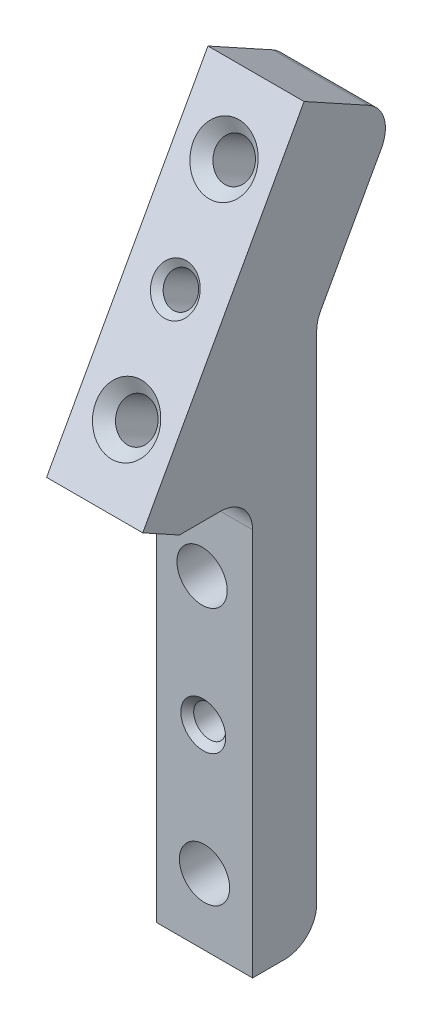
from build123d import *

# Parameters (mm, degrees)
BOSS_EXTRUDE1_DEPTH                    = 9.525
SKETCH2_W                              = 9.525
SKETCH2_H                              = 29.633356585
BOSS_EXTRUDE2_DEPTH                    = 10.5
BOSS_EXTRUDE3_DEPTH                    = 9.525
CUT_EXTRUDE1_DEPTH                     = 9.525
FILLET1_R                              = 3.175
F_10_24_TAPPED_HOLE1_D                 = 3.7973
F_10_24_TAPPED_HOLE1_DEPTH             = 12.83
F_10_24_TAPPED_HOLE1_CSINK_D           = 6.096
F_10_24_TAPPED_HOLE1_CSINK_ANGLE       = 90
F_10_24_TAPPED_HOLE1_TIP               = 1.140824014
F_1_8_0_125_DIAMETER_HOLE1_D           = 3.175
F_1_8_0_125_DIAMETER_HOLE1_DEPTH       = 8
F_1_8_0_125_DIAMETER_HOLE1_CSINK_D     = 4.445
F_1_8_0_125_DIAMETER_HOLE1_CSINK_ANGLE = 90
F_1_8_0_125_DIAMETER_HOLE1_TIP         = 0.953866233
F_10_CLEARANCE_HOLE1_D                 = 4.9784


with BuildPart() as part:
    # Sketch1 → Boss-Extrude1 (new body)
    with BuildSketch(Plane(origin=(0, 0, 0), x_dir=(0, 0, -1), z_dir=(1, 0, 0))):
        Polygon((0, 0), (13.510509947, 24.524806237), (7.948634247, 27.588796886), (-6.35, 1.633356585), (-6.35, -40), (0, -40), align=None)
    extrude(amount=BOSS_EXTRUDE1_DEPTH)

    # Sketch2 → Boss-Extrude2 (add)
    with BuildSketch(Plane(origin=(0, 3.063990649, 5.5618757), x_dir=(1, 0, 0), z_dir=(0, 0.482518212, 0.875885937))):
        with Locations((4.7625, 13.183321707)):
            Rectangle(SKETCH2_W, SKETCH2_H)
    extrude(amount=BOSS_EXTRUDE2_DEPTH)

    # Sketch3 → Boss-Extrude3 (add)
    with BuildSketch(Plane.ZY):
        Polygon((15.546802339, 6.699797816), (6.35, 1.633356585), (13.599802436, 1.633356585), (17.234729075, 3.635807167), align=None)
    extrude(amount=-BOSS_EXTRUDE3_DEPTH)

    # Sketch4 → Cut-Extrude1 (cut)
    with BuildSketch(Plane(origin=(9.525, 0, 0), x_dir=(0, 0, -1), z_dir=(1, 0, 0))):
        Polygon((13.510509947, 24.524806237), (7.948634247, 27.588796886), (0, 13.160125021), (0, 0), align=None)
    extrude(amount=-CUT_EXTRUDE1_DEPTH, mode=Mode.SUBTRACT)

    # Fillet1
    fillet1_edges = [part.edges().sort_by_distance(p)[0] for p in [
        (4.7625, -40, 0),
        (4.7625, 1.633356585, 6.35),
        (4.7625, 27.588796886, -7.948634247),
        (4.7625, 13.160125021, 0),
    ]]
    fillet(fillet1_edges, radius=FILLET1_R)

    # #10-24 Tapped Hole1
    with Locations(Plane(origin=(0, 8.130431879, 14.758678039), x_dir=(1, 0, 0), z_dir=(0, 0.482518212, 0.875885937))):
        with Locations((4.7625, 21.434240851), (4.7625, 1.434240851)):
            CounterSinkHole(F_10_24_TAPPED_HOLE1_D / 2, F_10_24_TAPPED_HOLE1_CSINK_D / 2, depth=F_10_24_TAPPED_HOLE1_DEPTH, counter_sink_angle=F_10_24_TAPPED_HOLE1_CSINK_ANGLE)
            with Locations((0, 0, -(F_10_24_TAPPED_HOLE1_DEPTH + F_10_24_TAPPED_HOLE1_TIP / 2))):  # 118° drill point
                Cone(0, F_10_24_TAPPED_HOLE1_D / 2, F_10_24_TAPPED_HOLE1_TIP, mode=Mode.SUBTRACT)

    # 1/8 (0.125) Diameter Hole1
    with Locations(Plane(origin=(0, 8.130431879, 14.758678039), x_dir=(1, 0, 0), z_dir=(0, 0.482518212, 0.875885937))):
        with Locations((4.7625, 11.434240851)):
            CounterSinkHole(F_1_8_0_125_DIAMETER_HOLE1_D / 2, F_1_8_0_125_DIAMETER_HOLE1_CSINK_D / 2, depth=F_1_8_0_125_DIAMETER_HOLE1_DEPTH, counter_sink_angle=F_1_8_0_125_DIAMETER_HOLE1_CSINK_ANGLE)
            with Locations((0, 0, -(F_1_8_0_125_DIAMETER_HOLE1_DEPTH + F_1_8_0_125_DIAMETER_HOLE1_TIP / 2))):  # 118° drill point
                Cone(0, F_1_8_0_125_DIAMETER_HOLE1_D / 2, F_1_8_0_125_DIAMETER_HOLE1_TIP, mode=Mode.SUBTRACT)

    # #10 Clearance Hole1 (through all)
    with Locations(Plane.XY.offset(6.35)):
        with Locations((4.7625, -33.418643415), (4.519767079, -8.018643415)):
            Hole(F_10_CLEARANCE_HOLE1_D / 2)

    # Sketch12 → 1/8 (0.125) Diameter Hole2 (revolve, cut)
    with BuildSketch(Plane(origin=(4.641133539, -20.718643415, 6.35), x_dir=(0, -1, 0), z_dir=(1, 0, 0))):
        Polygon((0, 0), (0, 6.35), (2.2225, 6.35), (1.5875, 5.715), (1.5875, 0.635), (2.2225, 0), align=None)
    revolve(axis=Axis((4.641133539, -20.718643415, 12.7), (0, 0, -1)), mode=Mode.SUBTRACT)


solid = part.part
